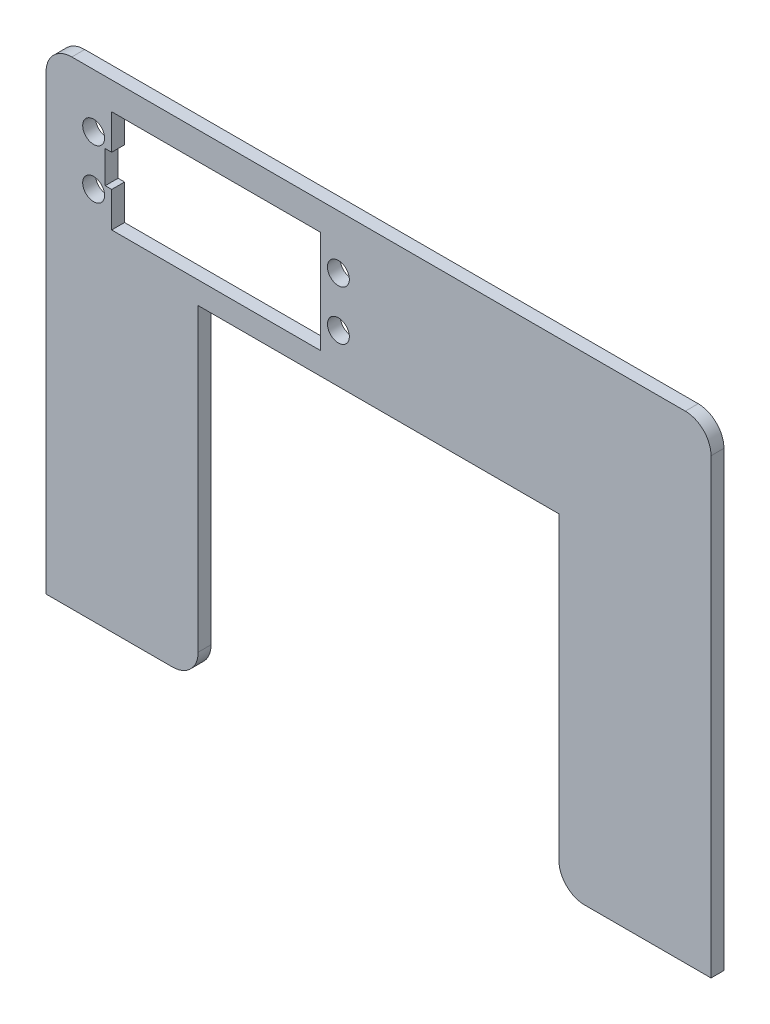
from build123d import *

# Parameters (mm, degrees)
BOSS_EXTRUDE1_DEPTH = 2.54
SKETCH2_R           = 2.159
CUT_EXTRUDE1_DEPTH  = 2.54
FILLET1_R           = 5.08
SKETCH3_W           = 2.54
SKETCH3_H           = 6.35
CUT_EXTRUDE4_DEPTH  = 3.54


with BuildPart() as part:
    # Sketch1 → Boss-Extrude1 (new body)
    with BuildSketch(Plane.XY):
        Polygon((35.56, -47.131), (35.56, 17.131), (-35.56, 17.131), (-35.56, -47.131), (-65.56, -47.131), (-65.56, 47.131), (65.56, 47.131), (65.56, -47.131), align=None)
    extrude(amount=BOSS_EXTRUDE1_DEPTH)

    # Sketch2 → Cut-Extrude1 (cut)
    with BuildSketch(Plane.XY.offset(2.54)):
        with Locations((-56.181, 36.4985)):
            Circle(SKETCH2_R)
        with Locations((-56.181, 26.7195)):
            Circle(SKETCH2_R)
        with Locations((-7.921, 36.4985)):
            Circle(SKETCH2_R)
        with Locations((-7.921, 26.7195)):
            Circle(SKETCH2_R)
        Polygon((-11.477, 41.7055), (-52.625, 41.7055), (-52.625, 21.5125), (-11.477, 21.5125), (-11.477, 31.609), align=None)
    extrude(amount=-CUT_EXTRUDE1_DEPTH, mode=Mode.SUBTRACT)

    # Fillet1
    fillet1_edges = [part.edges().sort_by_distance(p)[0] for p in [
        (-65.56, 47.131, 1.27),
        (65.56, 47.131, 1.27),
        (35.56, -47.131, 1.27),
        (-35.56, -47.131, 1.27),
    ]]
    fillet(fillet1_edges, radius=FILLET1_R)

    # Sketch3 → Cut-Extrude4 (cut, through all)
    with BuildSketch(Plane.XY.offset(2.54)):
        with Locations((-52.625, 31.609)):
            Rectangle(SKETCH3_W, SKETCH3_H)
    extrude(amount=-CUT_EXTRUDE4_DEPTH, mode=Mode.SUBTRACT)


solid = part.part
